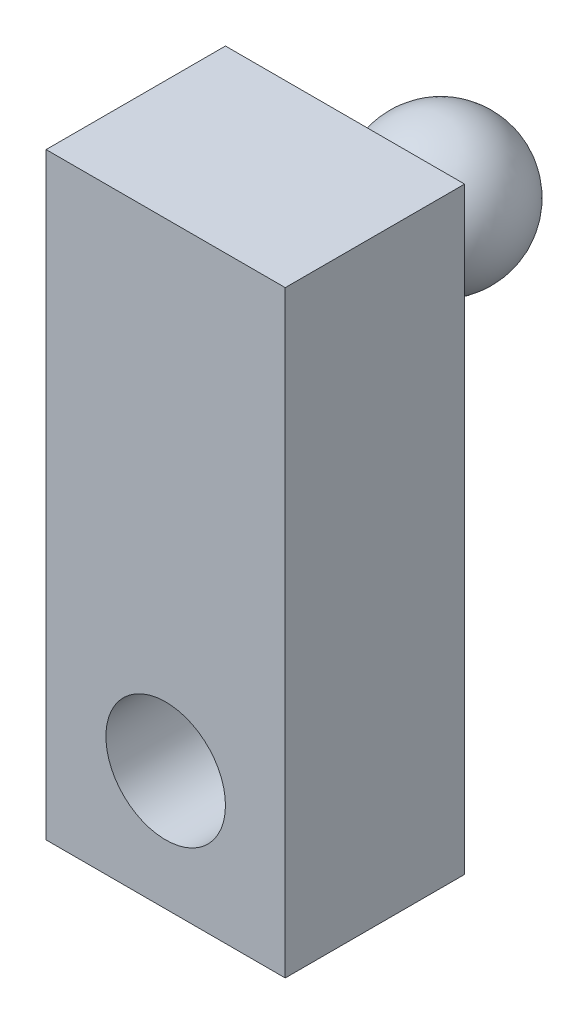
from build123d import *

# Parameters (mm, degrees)
SKETCH1_W           = 25.4
SKETCH1_H           = 63.5
SKETCH1_R           = 6.35
BOSS_EXTRUDE1_DEPTH = 19.05
SKETCH3_R           = 6.35
BOSS_EXTRUDE3_DEPTH = 2.54


with BuildPart() as part:
    # Sketch1 → Boss-Extrude1 (new body)
    with BuildSketch(Plane.XY):
        with Locations((12.7, 31.75)):
            Rectangle(SKETCH1_W, SKETCH1_H)
        with Locations((12.7, 12.7)):
            Circle(SKETCH1_R, mode=Mode.SUBTRACT)
    extrude(amount=BOSS_EXTRUDE1_DEPTH)

    # Sketch3 → Boss-Extrude3 (add)
    with BuildSketch(Plane(origin=(0, 0, 0), x_dir=(-1, 0, 0), z_dir=(0, 0, -1))):
        with Locations((-12.7, 50.8)):
            Circle(SKETCH3_R)
    extrude(amount=BOSS_EXTRUDE3_DEPTH)


with BuildPart() as body_2:
    # Sketch4 → Revolve1 (revolve)
    with BuildSketch(Plane(origin=(0, 0, -10.16), x_dir=(-1, 0, 0), z_dir=(0, 0, -1))):
        with BuildLine():
            Line((-12.7, 58.42), (-12.7, 43.18))
            ThreePointArc((-12.7, 43.18), (-20.32, 50.8), (-12.7, 58.42))
        make_face()
    revolve(axis=Axis((12.7, 58.42, -10.16), (0, -1, 0)))


solid = Compound([part.part, body_2.part])
